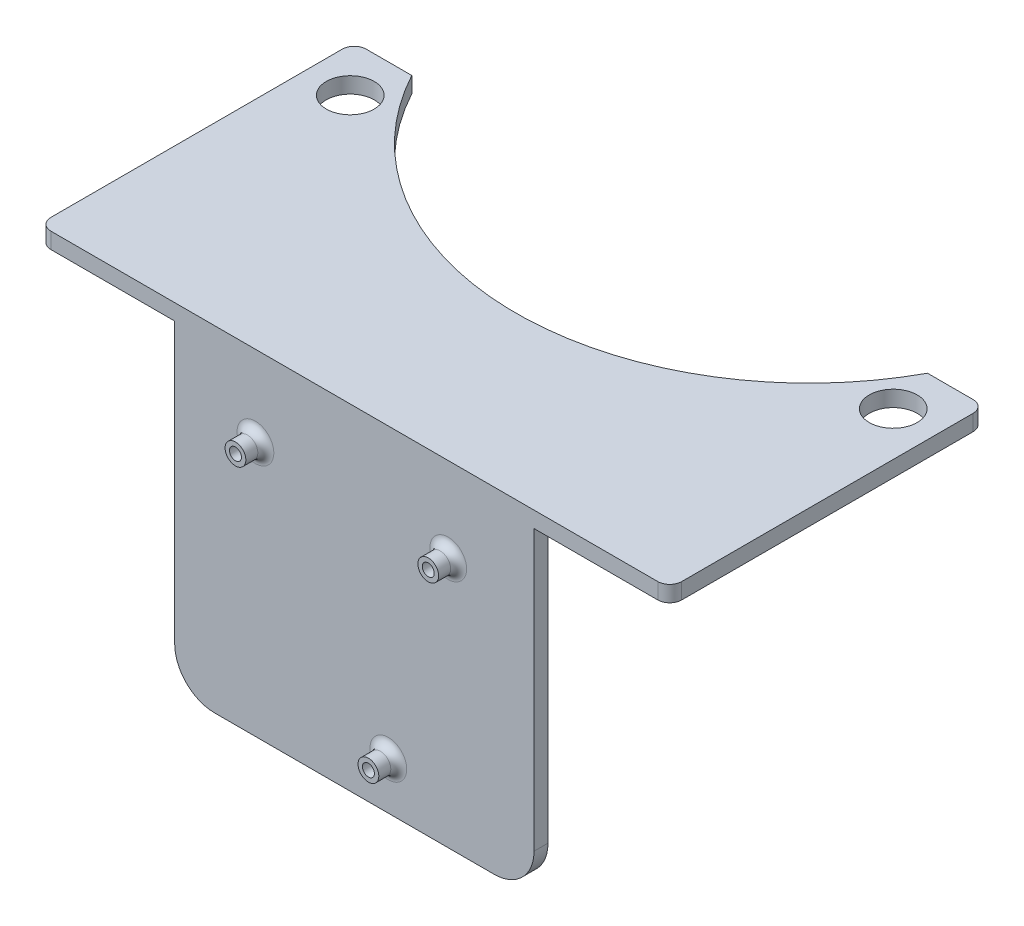
from build123d import *

# Parameters (mm, degrees)
SKETCH_217_R        = 6
EXTRUDE_1_DEPTH     = 4
SKETCH_2_W          = 3.5
SKETCH_2_H          = 80
EXTRUDE_3_DEPTH     = 45
EXTRUDE_4_DEPTH     = 14.5
SKETCH_10_R         = 2.6
SKETCH_10_R_2       = 1.5
EXTRUDE_5_DEPTH     = 5
FILLET_1_R          = 2
FILLET_2_R          = 2
FILLET_3_R          = 10
FILLET_4_R          = 10
FILLET_5_R          = 5
SKETCH_12_R         = 1.5
CUT_EXTRUDE_1_DEPTH = 5


with BuildPart() as part:
    # Sketch 217 → 凸台-拉伸1 (new body)
    with BuildSketch(Plane(origin=(0, 0, 0), x_dir=(1, 0, 0), z_dir=(0, 1, 0))):
        with BuildLine():
            Line((79, 11.520697427), (79, 84.492095777))
            ThreePointArc((79, 84.492095777), (78.121320344, 86.613416121), (76, 87.492095777))
            Line((76, 87.492095777), (64.588699332, 87.492095777))
            ThreePointArc((64.588699332, 87.492095777), (0, 48.976277018), (-64.588699332, 87.492095777))
            Line((-64.588699332, 87.492095777), (-76, 87.492095777))
            ThreePointArc((-76, 87.492095777), (-78.121320344, 86.613416121), (-79, 84.492095777))
            Line((-79, 84.492095777), (-79, 11.520698809))
            ThreePointArc((-79, 11.520698809), (-78.121320344, 9.399378465), (-76, 8.520698809))
            Line((-76, 8.520698809), (76.002879086, 8.520698809))
            ThreePointArc((76.002879086, 8.520698809), (78.12233801, 9.400395239), (79, 11.520697427))
        make_face()
        with Locations(Location((68, 75.492095777, 0), (0, 0, 270))):  # turned: the seam where the file's is
            Circle(SKETCH_217_R, mode=Mode.SUBTRACT)
        with Locations(Location((-68, 75.492095777, 0), (0, 0, 270))):  # turned: the seam where the file's is
            Circle(SKETCH_217_R, mode=Mode.SUBTRACT)
    extrude(amount=EXTRUDE_1_DEPTH)

    # 草图2 → 凸台-拉伸3 (add, symmetric)
    with BuildSketch(Plane(origin=(0, 0, 0), x_dir=(0, 0, -1), z_dir=(1, 0, 0))):
        with Locations((10.270698809, -40)):
            Rectangle(SKETCH_2_W, SKETCH_2_H)
    extrude(amount=EXTRUDE_3_DEPTH, both=True)

    # 草图11 → 凸台-拉伸4 (add, symmetric)
    with BuildSketch(Plane(origin=(0, 0, 0), x_dir=(0, 0, -1), z_dir=(1, 0, 0))):
        Polygon((22.519495234, 0), (25.319495234, 0), (25.319495234, -13.290347232), (12.020698809, -28.288925016), (12.020698809, -25.13708489), (22.519495234, -13.2963882), align=None)
    extrude(amount=EXTRUDE_4_DEPTH, both=True)

    # 草图10 → 凸台-拉伸5 (add)
    with BuildSketch(Plane.XY.offset(-8.520698809)):
        with Locations(Location((23.511926173, -17.207974392, 0), (0, 0, 180))):  # turned: the seam where the file's is
            Circle(SKETCH_10_R)
        with Locations(Location((23.511926173, -17.207974392, 0), (0, 0, 180))):  # turned: the seam where the file's is
            Circle(SKETCH_10_R_2, mode=Mode.SUBTRACT)
        with Locations(Location((-24.77772075, -16.207974392, 0), (0, 0, 180))):  # turned: the seam where the file's is
            Circle(SKETCH_10_R)
        with Locations(Location((-24.77772075, -16.207974392, 0), (0, 0, 180))):  # turned: the seam where the file's is
            Circle(SKETCH_10_R_2, mode=Mode.SUBTRACT)
        with Locations(Location((8.524325101, -68.1489384, 0), (0, 0, 180))):  # turned: the seam where the file's is
            Circle(SKETCH_10_R)
        with Locations(Location((8.524325101, -68.1489384, 0), (0, 0, 180))):  # turned: the seam where the file's is
            Circle(SKETCH_10_R_2, mode=Mode.SUBTRACT)
    extrude(amount=EXTRUDE_5_DEPTH)

    # 圆角1
    fillet_1_edges = [part.edges().sort_by_distance(p)[0] for p in [
        (11.124325101, -68.1489384, -8.520698809),
    ]]
    fillet(fillet_1_edges, radius=FILLET_1_R)

    # 圆角2
    fillet_2_edges = [part.edges().sort_by_distance(p)[0] for p in [
        (26.111926173, -17.207974392, -8.520698809),
        (-22.17772075, -16.207974392, -8.520698809),
    ]]
    fillet(fillet_2_edges, radius=FILLET_2_R)

    # 圆角3
    fillet_3_edges = [part.edges().sort_by_distance(p)[0] for p in [
        (45, -80, -10.270698809),
    ]]
    fillet(fillet_3_edges, radius=FILLET_3_R)

    # 圆角4
    fillet_4_edges = [part.edges().sort_by_distance(p)[0] for p in [
        (-45, -80, -10.270698809),
    ]]
    fillet(fillet_4_edges, radius=FILLET_4_R)

    # 圆角5
    fillet_5_edges = [part.edges().sort_by_distance(p)[0] for p in [
        (0, 0, -25.319495234),
    ]]
    fillet(fillet_5_edges, radius=FILLET_5_R)

    # 草图12 → 切除-拉伸1 (cut)
    with BuildSketch(Plane.XY.offset(-8.520698809)):
        with Locations(Location((-24.77772075, -16.207974392, 0), (0, 0, 180))):  # turned: the seam where the file's is
            Circle(SKETCH_12_R)
        with Locations(Location((23.511926173, -17.207974392, 0), (0, 0, 180))):  # turned: the seam where the file's is
            Circle(SKETCH_12_R)
        with Locations(Location((8.524325101, -68.1489384, 0), (0, 0, 180))):  # turned: the seam where the file's is
            Circle(SKETCH_12_R)
    extrude(amount=-CUT_EXTRUDE_1_DEPTH, mode=Mode.SUBTRACT)


solid = part.part
